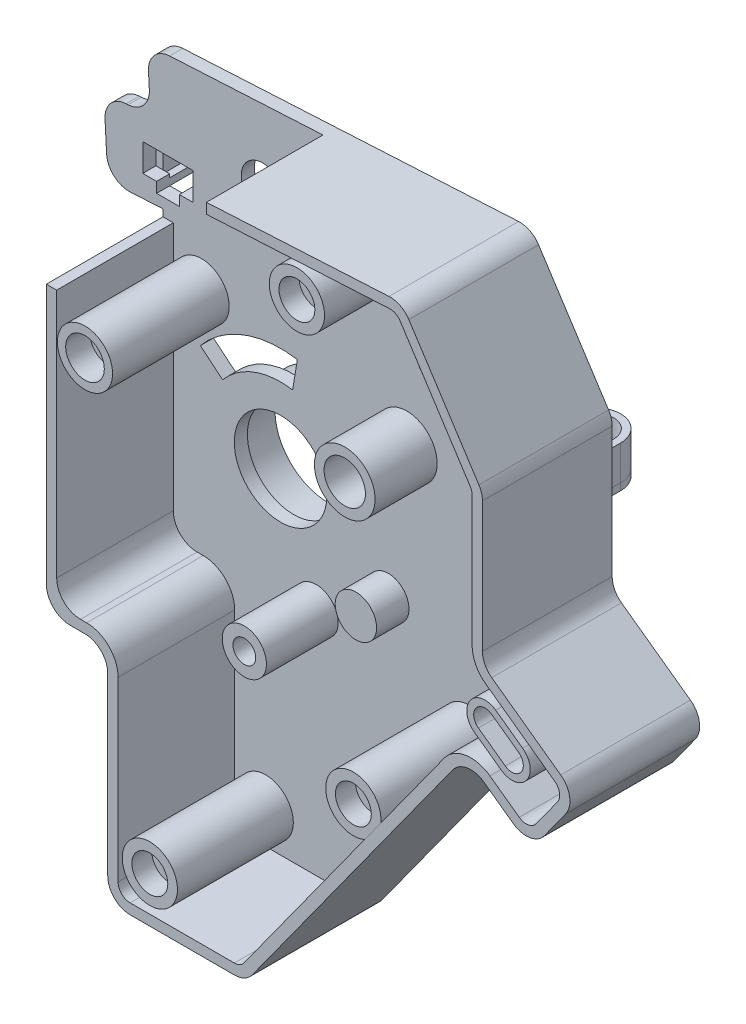
from build123d import *

# Parameters (mm, degrees)
BOSS_EXTRUDE1_DEPTH  = 1.9
BOSS_EXTRUDE8_DEPTH  = 16.9
SKETCH6_R            = 4
SKETCH6_R_2          = 2.6
BOSS_EXTRUDE3_DEPTH  = 16.8
SKETCH8_R            = 6.71
SKETCH8_R_2          = 3.1
SKETCH8_R_3          = 5
CUT_EXTRUDE2_DEPTH   = 1.9
SKETCH9_R            = 4.4
SKETCH9_R_2          = 3
BOSS_EXTRUDE4_DEPTH  = 9
SKETCH10_R           = 3
BOSS_EXTRUDE5_DEPTH  = 4.7
SKETCH11_R           = 3.2
SKETCH11_R_2         = 1.65
BOSS_EXTRUDE6_DEPTH  = 10.4
SKETCH12_R           = 4
BOSS_EXTRUDE7_DEPTH  = 16.9
SKETCH13_R           = 2.8
CUT_EXTRUDE3_DEPTH   = 3.5
CUT_EXTRUDE4_DEPTH   = 16.9
FILLET1_R            = 3.24
FILLET2_R            = 3.24
FILLET3_R            = 3.24
FILLET4_R            = 3.24
FILLET7_R            = 3.45
FILLET8_R            = 3.45
FILLET9_R            = 4.56
FILLET10_R           = 3.33
CUT_EXTRUDE8_DEPTH   = 10
BOSS_EXTRUDE9_DEPTH  = 1
BOSS_EXTRUDE10_DEPTH = 5
BOSS_EXTRUDE11_DEPTH = 1
BOSS_EXTRUDE12_DEPTH = 5
SKETCH23_W           = 16.9
SKETCH23_H           = 1.50215582
CUT_EXTRUDE9_DEPTH   = 2
CUT_EXTRUDE11_DEPTH  = 16.9
SKETCH26_W           = 16.9
SKETCH26_H           = 2.606851164
CUT_EXTRUDE12_DEPTH  = 1.5
SKETCH27_R           = 8.71
SKETCH27_R_2         = 7.71
BOSS_EXTRUDE13_DEPTH = 5
SKETCH28_R           = 2.6
CUT_EXTRUDE13_DEPTH  = 10
SKETCH30_R           = 4
SKETCH30_R_2         = 1.3
BOSS_EXTRUDE14_DEPTH = 1
BOSS_EXTRUDE15_DEPTH = 16.7
BOSS_EXTRUDE16_DEPTH = 12.13


with BuildPart() as part:
    # Sketch1 → Boss-Extrude1 (new body)
    with BuildSketch(Plane.XY):
        with BuildLine():
            Line((3.24, 0), (18.342721738, 0))
            ThreePointArc((18.342721738, 0), (19.818183811, 0.355452952), (20.96990678, 1.343819957))
            Line((20.96990678, 1.343819957), (49.999441051, 41.564662113))
            ThreePointArc((49.999441051, 41.564662113), (52.109727501, 42.866984196), (54.522806136, 42.295667112))
            Line((54.522806136, 42.295667112), (58.77171034, 39.229005561))
            ThreePointArc((58.77171034, 39.229005561), (61.184788975, 38.657688478), (63.295075425, 39.96001056))
            Line((63.295075425, 39.96001056), (66.385146606, 44.241349147))
            ThreePointArc((66.385146606, 44.241349147), (66.956463689, 46.654427782), (65.654141607, 48.764714232))
            Line((65.654141607, 48.764714232), (55.662144624, 55.976473193))
            ThreePointArc((55.662144624, 55.976473193), (54.67377762, 57.128196162), (54.318324667, 58.603658235))
            Line((54.318324667, 58.603658235), (54.318324667, 77.488493275))
            ThreePointArc((54.318324667, 77.488493275), (54.185382003, 78.407076266), (53.797463734, 79.250277239))
            Line((53.797463734, 79.250277239), (43.647307388, 94.916038315))
            ThreePointArc((43.647307388, 94.916038315), (42.398845609, 96.041243841), (40.754646969, 96.389604462))
            Line((40.754646969, 96.389604462), (-11.170725181, 93.604693865))
            Line((-11.170725181, 93.604693865), (-10.699432619, 84.817323193))
            Line((-10.699432619, 84.817323193), (-17.469702295, 84.454213696))
            Line((-17.469702295, 84.454213696), (-16.891297787, 73.669713326))
            Line((-16.891297787, 73.669713326), (-8.9, 74.098310156))
            Line((-8.9, 74.098310156), (-8.9, 59.47))
            Line((-8.9, 59.47), (-8.9, 32))
            Line((-8.9, 32), (0, 32))
            Line((0, 32), (0, 3.24))
            ThreePointArc((0, 3.24), (0.948974029, 0.948974029), (3.24, 0))
        make_face()
    extrude(amount=BOSS_EXTRUDE1_DEPTH)

    # Sketch16 → Boss-Extrude8 (add)
    with BuildSketch(Plane.XY.offset(1.9)):
        with BuildLine():
            Line((-8.9, 74.098310156), (-8.9, 32))
            Line((-8.9, 32), (0, 32))
            Line((0, 32), (0, 3.24))
            ThreePointArc((0, 3.24), (0.948974029, 0.948974029), (3.24, 0))
            Line((3.24, 0), (18.342721738, 0))
            ThreePointArc((18.342721738, 0), (19.818183811, 0.355452952), (20.96990678, 1.343819957))
            Line((20.96990678, 1.343819957), (49.999441051, 41.564662113))
            ThreePointArc((49.999441051, 41.564662113), (52.109727501, 42.866984196), (54.522806136, 42.295667112))
            Line((54.522806136, 42.295667112), (58.77171034, 39.229005561))
            ThreePointArc((58.77171034, 39.229005561), (61.184788975, 38.657688478), (63.295075425, 39.96001056))
            Line((63.295075425, 39.96001056), (66.385146606, 44.241349147))
            ThreePointArc((66.385146606, 44.241349147), (66.956463689, 46.654427782), (65.654141607, 48.764714232))
            Line((65.654141607, 48.764714232), (55.662144624, 55.976473193))
            ThreePointArc((55.662144624, 55.976473193), (54.67377762, 57.128196162), (54.318324667, 58.603658235))
            Line((54.318324667, 58.603658235), (54.318324667, 77.488493275))
            ThreePointArc((54.318324667, 77.488493275), (54.185382003, 78.407076266), (53.797463734, 79.250277239))
            Line((53.797463734, 79.250277239), (43.647307388, 94.916038315))
            ThreePointArc((43.647307388, 94.916038315), (42.398845609, 96.041243841), (40.754646969, 96.389604462))
            Line((40.754646969, 96.389604462), (-11.170725181, 93.604693865))
            Line((-11.170725181, 93.604693865), (-10.699432619, 84.817323193))
            Line((-10.699432619, 84.817323193), (-17.469702295, 84.454213696))
            Line((-17.469702295, 84.454213696), (-16.891297787, 73.669713326))
            Line((-16.891297787, 73.669713326), (-8.9, 74.098310156))
        make_face()
        with BuildLine():
            Line((-15.891521062, 83.036700382), (-15.473784473, 75.247894559))
            Line((-15.473784473, 75.247894559), (-7.4, 75.680915393))
            Line((-7.4, 75.680915393), (-7.4, 33.5))
            Line((-7.4, 33.5), (1.5, 33.5))
            Line((1.5, 33.5), (1.5, 3.24))
            ThreePointArc((1.5, 3.24), (2.009634201, 2.009634201), (3.24, 1.5))
            Line((3.24, 1.5), (18.342721738, 1.5))
            ThreePointArc((18.342721738, 1.5), (19.135099518, 1.6908914), (19.753617409, 2.221681088))
            Line((19.753617409, 2.221681088), (48.78315168, 42.442523245))
            ThreePointArc((48.78315168, 42.442523245), (51.870422598, 44.347772217), (55.400667267, 43.511956484))
            Line((55.400667267, 43.511956484), (59.649571471, 40.445294932))
            ThreePointArc((59.649571471, 40.445294932), (60.945484071, 40.138476499), (62.078786054, 40.837871691))
            Line((62.078786054, 40.837871691), (65.168857235, 45.119210278))
            ThreePointArc((65.168857235, 45.119210278), (65.475675668, 46.415122878), (64.776280476, 47.548424861))
            Line((64.776280476, 47.548424861), (54.784283493, 54.760183822))
            ThreePointArc((54.784283493, 54.760183822), (53.338339172, 56.445111868), (52.818324667, 58.603658235))
            Line((52.818324667, 58.603658235), (52.818324667, 77.488493275))
            ThreePointArc((52.818324667, 77.488493275), (52.746929533, 77.981806363), (52.538603055, 78.434636515))
            Line((52.538603055, 78.434636515), (42.38844671, 94.100397591))
            ThreePointArc((42.38844671, 94.100397591), (41.717976495, 94.704674633), (40.834980929, 94.891757188))
            Line((40.834980929, 94.891757188), (-9.592543948, 92.187180551))
            Line((-9.592543948, 92.187180551), (-9.121251386, 83.399809879))
            Line((-9.121251386, 83.399809879), (-15.891521062, 83.036700382))
        make_face(mode=Mode.SUBTRACT)
    extrude(amount=BOSS_EXTRUDE8_DEPTH)

    # Sketch6 → Boss-Extrude3 (add)
    with BuildSketch(Plane.XY.offset(1.9)):
        with Locations((6, 6.5)):
            Circle(SKETCH6_R)
        with Locations((6, 6.5)):
            Circle(SKETCH6_R_2, mode=Mode.SUBTRACT)
        with Locations((35.5, 30)):
            Circle(SKETCH6_R)
        with Locations((35.5, 30)):
            Circle(SKETCH6_R_2, mode=Mode.SUBTRACT)
        with Locations((27.32, 89.23)):
            Circle(SKETCH6_R)
        with Locations((27.32, 89.23)):
            Circle(SKETCH6_R_2, mode=Mode.SUBTRACT)
    extrude(amount=BOSS_EXTRUDE3_DEPTH)

    # Sketch8 → Cut-Extrude2 (cut)
    with BuildSketch(Plane.XY.offset(1.9)):
        with Locations((8.15, 50)):
            Circle(SKETCH8_R)
        with Locations((5.55, 83.99)):
            Circle(SKETCH8_R_2)
        with Locations((32.568324667, 75.4)):
            Circle(SKETCH8_R_3)
        with BuildLine():
            Line((10.580849078, 64.913184528), (9.905166343, 60.767891674))
            ThreePointArc((9.905166343, 60.767891674), (4.322700656, 60.216647187), (-0.247931136, 56.964398942))
            Line((-0.247931136, 56.964398942), (-3.480865213, 59.645469113))
            ThreePointArc((-3.480865213, 59.645469113), (2.849313191, 64.149728597), (10.580849078, 64.913184528))
        make_face()
    extrude(amount=-CUT_EXTRUDE2_DEPTH, mode=Mode.SUBTRACT)

    # Sketch9 → Boss-Extrude4 (add)
    with BuildSketch(Plane.XY.offset(1.9)):
        with Locations((26.45, 62)):
            Circle(SKETCH9_R)
        with Locations((26.45, 62)):
            Circle(SKETCH9_R_2, mode=Mode.SUBTRACT)
    extrude(amount=BOSS_EXTRUDE4_DEPTH)

    # Sketch10 → Boss-Extrude5 (add)
    with BuildSketch(Plane.XY.offset(1.9)):
        with Locations((23.77, 41.68)):
            Circle(SKETCH10_R)
    extrude(amount=BOSS_EXTRUDE5_DEPTH)

    # Sketch11 → Boss-Extrude6 (add)
    with BuildSketch(Plane.XY.offset(1.9)):
        with Locations((13.3, 34.85)):
            Circle(SKETCH11_R)
        with Locations((13.3, 34.85)):
            Circle(SKETCH11_R_2, mode=Mode.SUBTRACT)
    extrude(amount=BOSS_EXTRUDE6_DEPTH)

    # Sketch12 → Boss-Extrude7 (add)
    with BuildSketch(Plane.XY.offset(1.9)):
        with Locations((-3.3, 66.65)):
            Circle(SKETCH12_R)
    extrude(amount=BOSS_EXTRUDE7_DEPTH)

    # Sketch13 → Cut-Extrude3 (cut)
    with BuildSketch(Plane.XY.offset(18.8)):
        with Locations((-3.3, 66.65)):
            Circle(SKETCH13_R)
    extrude(amount=-CUT_EXTRUDE3_DEPTH, mode=Mode.SUBTRACT)

    # Sketch17 → Cut-Extrude4 (cut)
    with BuildSketch(Plane.XY.offset(18.8)):
        Polygon((-8.9, 73.098310156), (-7.4, 73.098310156), (-7.4, 75.680915393), (-15.473784473, 75.247894559), (-15.891521062, 83.036700382), (-9.121251386, 83.399809879), (-9.592543948, 92.187180551), (10.797701498, 93.280769451), (10.797701498, 94.782925271), (-11.170725181, 93.604693865), (-10.699432619, 84.817323193), (-17.469702295, 84.454213696), (-16.891297787, 73.669713326), (-8.9, 74.098310156), align=None)
    extrude(amount=-CUT_EXTRUDE4_DEPTH, mode=Mode.SUBTRACT)

    # Fillet1
    fillet1_edges = [part.edges().sort_by_distance(p)[0] for p in [
        (-17.469702295, 84.454213696, 0.95),
    ]]
    fillet(fillet1_edges, radius=FILLET1_R)

    # Fillet2
    fillet2_edges = [part.edges().sort_by_distance(p)[0] for p in [
        (-10.699432619, 84.817323193, 0.95),
    ]]
    fillet(fillet2_edges, radius=FILLET2_R)

    # Fillet3
    fillet3_edges = [part.edges().sort_by_distance(p)[0] for p in [
        (-11.170725181, 93.604693865, 0.95),
    ]]
    fillet(fillet3_edges, radius=FILLET3_R)

    # Fillet4
    fillet4_edges = [part.edges().sort_by_distance(p)[0] for p in [
        (-16.891297787, 73.669713326, 0.95),
    ]]
    fillet(fillet4_edges, radius=FILLET4_R)

    # Fillet7
    fillet7_edges = [part.edges().sort_by_distance(p)[0] for p in [
        (-8.9, 32, 9.4),
    ]]
    fillet(fillet7_edges, radius=FILLET7_R)

    # Fillet8
    fillet8_edges = [part.edges().sort_by_distance(p)[0] for p in [
        (-7.4, 33.5, 10.35),
    ]]
    fillet(fillet8_edges, radius=FILLET8_R)

    # Fillet9
    fillet9_edges = [part.edges().sort_by_distance(p)[0] for p in [
        (1.5, 33.5, 10.35),
    ]]
    fillet(fillet9_edges, radius=FILLET9_R)

    # Fillet10
    fillet10_edges = [part.edges().sort_by_distance(p)[0] for p in [
        (0, 32, 9.4),
    ]]
    fillet(fillet10_edges, radius=FILLET10_R)

    # Sketch14 → Cut-Extrude8 (cut)
    with BuildSketch(Plane.XY.offset(1.9)):
        Polygon((44.25, 71.49), (51.55, 71.49), (51.55, 67.49), (49.55, 67.49), (49.55, 65.99), (46.25, 65.99), (46.25, 67.49), (44.25, 67.49), align=None)
        Polygon((-11.82, 81.09), (-4.52, 81.09), (-4.52, 77.09), (-6.52, 77.09), (-6.52, 75.59), (-9.82, 75.59), (-9.82, 77.09), (-11.82, 77.09), align=None)
    extrude(amount=-CUT_EXTRUDE8_DEPTH, mode=Mode.SUBTRACT)

    # Sketch19 → Boss-Extrude9 (add)
    with BuildSketch(Plane(origin=(0, 65.99, 0), x_dir=(1, 0, 0), z_dir=(0, 1, 0))):
        with BuildLine():
            Line((46.25, 4), (46.25, 0))
            Line((46.25, 0), (44.25, 0))
            Line((44.25, 0), (44.25, 4))
            ThreePointArc((44.25, 4), (47.9, 7.65), (51.55, 4))
            Line((51.55, 4), (51.55, 0))
            Line((51.55, 0), (49.55, 0))
            Line((49.55, 0), (49.55, 4))
            ThreePointArc((49.55, 4), (47.9, 5.65), (46.25, 4))
        make_face()
    extrude(amount=BOSS_EXTRUDE9_DEPTH)

    # Sketch21 → Boss-Extrude11 (add)
    with BuildSketch(Plane(origin=(0, 75.59, 0), x_dir=(1, 0, 0), z_dir=(0, 1, 0))):
        with BuildLine():
            Line((-9.82, 4), (-9.82, 0))
            Line((-9.82, 0), (-11.82, 0))
            Line((-11.82, 0), (-11.82, 4))
            ThreePointArc((-11.82, 4), (-8.17, 7.65), (-4.52, 4))
            Line((-4.52, 4), (-4.52, 0))
            Line((-4.52, 0), (-6.52, 0))
            Line((-6.52, 0), (-6.52, 4))
            ThreePointArc((-6.52, 4), (-8.17, 5.65), (-9.82, 4))
        make_face()
    extrude(amount=BOSS_EXTRUDE11_DEPTH)

    # Sketch23 → Cut-Extrude9 (cut)
    with BuildSketch(Plane.ZY.offset(-10.797701498)):
        with Locations((10.35, 94.031847361)):
            Rectangle(SKETCH23_W, SKETCH23_H)
    extrude(amount=-CUT_EXTRUDE9_DEPTH, mode=Mode.SUBTRACT)

    # Sketch25 → Cut-Extrude11 (cut)
    with BuildSketch(Plane.XY.offset(18.8)):
        Polygon((12.797701498, 94.782925271), (12.797701498, 94.89019116), (10.797701498, 94.782925271), align=None)
    extrude(amount=-CUT_EXTRUDE11_DEPTH, mode=Mode.SUBTRACT)

    # Sketch26 → Cut-Extrude12 (cut)
    with BuildSketch(Plane.ZY.offset(-12.797701498)):
        with Locations((10.35, 94.691460922)):
            Rectangle(SKETCH26_W, SKETCH26_H)
    extrude(amount=-CUT_EXTRUDE12_DEPTH, mode=Mode.SUBTRACT)

    # Sketch27 → Boss-Extrude13 (add)
    with BuildSketch(Plane(origin=(0, 0, 0), x_dir=(-1, 0, 0), z_dir=(0, 0, -1))):
        with Locations((-8.15, 50)):
            Circle(SKETCH27_R)
        with Locations((-8.15, 50)):
            Circle(SKETCH27_R_2, mode=Mode.SUBTRACT)
    extrude(amount=BOSS_EXTRUDE13_DEPTH)

    # Sketch28 → Cut-Extrude13 (cut)
    with BuildSketch(Plane.XY.offset(1.9)):
        with Locations((27.32, 89.23)):
            Circle(SKETCH28_R)
        with Locations((6, 6.5)):
            Circle(SKETCH28_R)
        with Locations((35.5, 30)):
            Circle(SKETCH28_R)
    extrude(amount=-CUT_EXTRUDE13_DEPTH, mode=Mode.SUBTRACT)

    # Sketch30 → Boss-Extrude14 (add)
    with BuildSketch(Plane.XY.offset(15.8)):
        with Locations((27.32, 89.23)):
            Circle(SKETCH30_R)
        with Locations((27.32, 89.23)):
            Circle(SKETCH30_R_2, mode=Mode.SUBTRACT)
        with Locations((6, 6.5)):
            Circle(SKETCH30_R)
        with Locations((6, 6.5)):
            Circle(SKETCH30_R_2, mode=Mode.SUBTRACT)
        with BuildLine():
            Line((37.184030003, 26.371771376), (39.47398455, 29.544536723))
            ThreePointArc((39.47398455, 29.544536723), (32.256561677, 32.340963016), (37.184030003, 26.371771376))
        make_face()
        with Locations((35.5, 30)):
            Circle(SKETCH30_R_2, mode=Mode.SUBTRACT)
    extrude(amount=-BOSS_EXTRUDE14_DEPTH)

    # Sketch31 → Boss-Extrude15 (add)
    with BuildSketch(Plane.XY.offset(1.9)):
        with BuildLine():
            Line((56.045702383, 51.975196389), (59.937828371, 49.16604077))
            ThreePointArc((59.937828371, 49.16604077), (60.535718262, 45.466374882), (56.836052375, 44.868484991))
            Line((56.836052375, 44.868484991), (52.943926387, 47.677640611))
            ThreePointArc((52.943926387, 47.677640611), (52.346036496, 51.377306498), (56.045702383, 51.975196389))
        make_face()
        with BuildLine():
            Line((55.460461629, 51.164336808), (59.352587617, 48.355181189))
            ThreePointArc((59.352587617, 48.355181189), (59.724858682, 46.051615636), (57.421293129, 45.679344572))
            Line((57.421293129, 45.679344572), (53.529167141, 48.488500192))
            ThreePointArc((53.529167141, 48.488500192), (53.156896077, 50.792065744), (55.460461629, 51.164336808))
        make_face(mode=Mode.SUBTRACT)
    extrude(amount=BOSS_EXTRUDE15_DEPTH)

    # Sketch32 → Boss-Extrude16 (add)
    with BuildSketch(Plane.XY.offset(1.9)):
        with BuildLine():
            Line((53.529167141, 48.488500192), (57.421293129, 45.679344572))
            ThreePointArc((57.421293129, 45.679344572), (59.724858682, 46.051615636), (59.352587617, 48.355181189))
            Line((59.352587617, 48.355181189), (55.460461629, 51.164336808))
            ThreePointArc((55.460461629, 51.164336808), (53.156896077, 50.792065744), (53.529167141, 48.488500192))
        make_face()
    extrude(amount=BOSS_EXTRUDE16_DEPTH)


with BuildPart() as body_2:
    # Sketch20 → Boss-Extrude10 (new body)
    with BuildSketch(Plane(origin=(0, 66.99, 0), x_dir=(1, 0, 0), z_dir=(0, 1, 0))):
        with BuildLine():
            Line((44.25, 0), (45.25, 0))
            Line((45.25, 0), (45.25, 4))
            ThreePointArc((45.25, 4), (47.9, 6.65), (50.55, 4))
            Line((50.55, 4), (50.55, 0))
            Line((50.55, 0), (51.55, 0))
            Line((51.55, 0), (51.55, 4))
            ThreePointArc((51.55, 4), (47.9, 7.65), (44.25, 4))
            Line((44.25, 4), (44.25, 0))
        make_face()
    extrude(amount=BOSS_EXTRUDE10_DEPTH)


with BuildPart() as body_3:
    # Sketch22 → Boss-Extrude12 (new body)
    with BuildSketch(Plane(origin=(0, 76.59, 0), x_dir=(1, 0, 0), z_dir=(0, 1, 0))):
        with BuildLine():
            Line((-11.82, 0), (-10.82, 0))
            Line((-10.82, 0), (-10.82, 4))
            ThreePointArc((-10.82, 4), (-8.17, 6.65), (-5.52, 4))
            Line((-5.52, 4), (-5.52, 0))
            Line((-5.52, 0), (-4.52, 0))
            Line((-4.52, 0), (-4.52, 4))
            ThreePointArc((-4.52, 4), (-8.17, 7.65), (-11.82, 4))
            Line((-11.82, 4), (-11.82, 0))
        make_face()
    extrude(amount=BOSS_EXTRUDE12_DEPTH)


solid = Compound([part.part, body_2.part, body_3.part])
